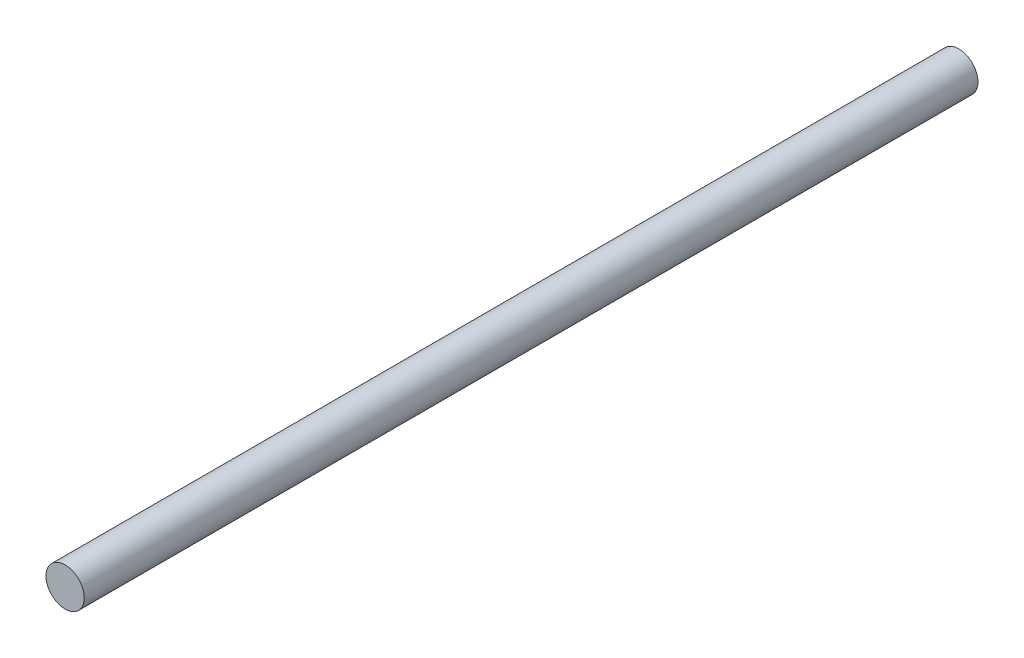
from build123d import *

# Parameters (mm, degrees)
CROQUIS1_R              = 7.5
SALIENTE_EXTRUIR1_DEPTH = 350


with BuildPart() as part:
    # Croquis1 → Saliente-Extruir1 (new body)
    with BuildSketch(Plane.XY):
        Circle(CROQUIS1_R)
    extrude(amount=SALIENTE_EXTRUIR1_DEPTH)


solid = part.part
